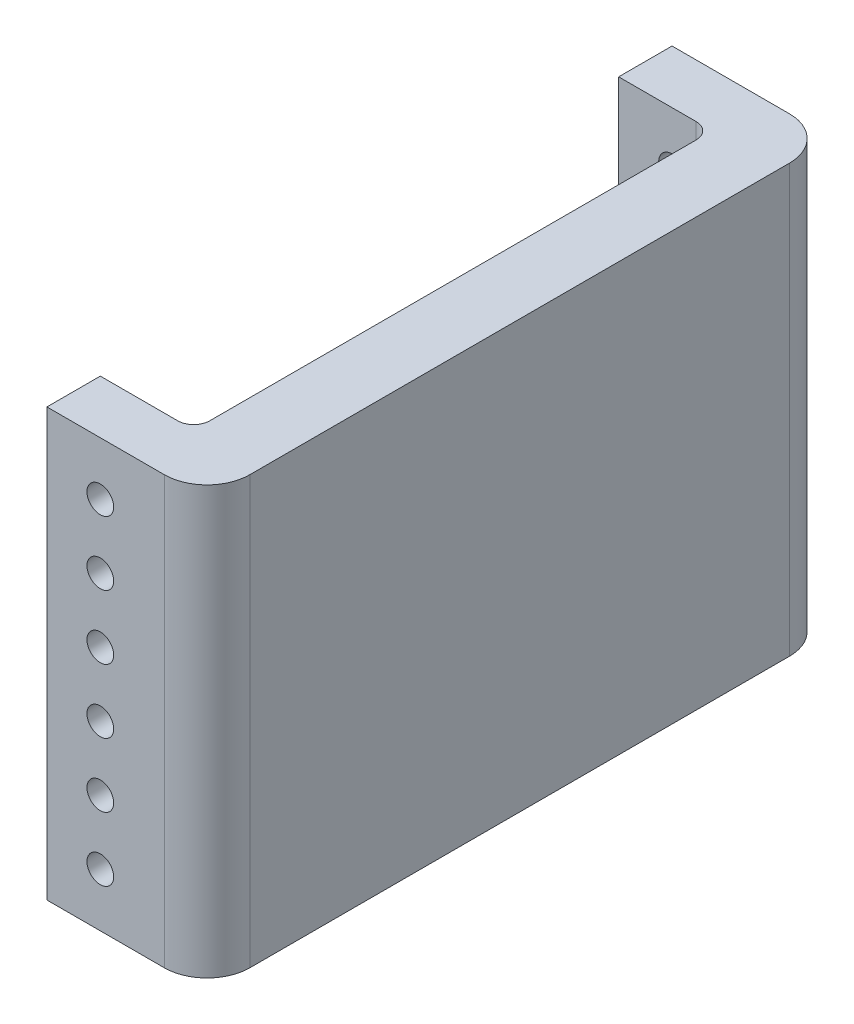
from build123d import *

# Parameters (mm, degrees)
SKETCH1_W           = 297.434
SKETCH1_H           = 203.2
BOSS_EXTRUDE1_DEPTH = 76.2
SKETCH3_W           = 44.45
SKETCH3_H           = 246.634
CUT_EXTRUDE1_DEPTH  = 204.2
SKETCH4_R           = 6.35
CUT_EXTRUDE2_DEPTH  = 298.434
FILLET1_R           = 20.32
FILLET2_R           = 7.62


with BuildPart() as part:
    # Sketch1 → Boss-Extrude1 (new body)
    with BuildSketch(Plane(origin=(0, 0, 0), x_dir=(0, 0, -1), z_dir=(1, 0, 0))):
        with Locations((-688.794526316, 662.857561404)):
            Rectangle(SKETCH1_W, SKETCH1_H)
    extrude(amount=BOSS_EXTRUDE1_DEPTH)

    # Sketch3 → Cut-Extrude1 (cut, through all)
    with BuildSketch(Plane(origin=(0, 764.457561404, 0), x_dir=(1, 0, 0), z_dir=(0, 1, 0))):
        with Locations((22.225, -688.794526316)):
            Rectangle(SKETCH3_W, SKETCH3_H)
    extrude(amount=-CUT_EXTRUDE1_DEPTH, mode=Mode.SUBTRACT)

    # Sketch4 → Cut-Extrude2 (cut, through all)
    with BuildSketch(Plane.XY.offset(837.511526316)):
        with Locations((25.4, 739.057561404)):
            Circle(SKETCH4_R)
        with Locations((25.4, 708.577561404)):
            Circle(SKETCH4_R)
        with Locations((25.4, 678.097561404)):
            Circle(SKETCH4_R)
        with Locations((25.4, 647.617561404)):
            Circle(SKETCH4_R)
        with Locations((25.4, 617.137561404)):
            Circle(SKETCH4_R)
        with Locations((25.4, 586.657561404)):
            Circle(SKETCH4_R)
    extrude(amount=-CUT_EXTRUDE2_DEPTH, mode=Mode.SUBTRACT)

    # Fillet1
    fillet1_edges = [part.edges().sort_by_distance(p)[0] for p in [
        (76.2, 662.857561404, 540.077526316),
        (76.2, 662.857561404, 837.511526316),
    ]]
    fillet(fillet1_edges, radius=FILLET1_R)

    # Fillet2
    fillet2_edges = [part.edges().sort_by_distance(p)[0] for p in [
        (44.45, 662.857561404, 565.477526316),
        (44.45, 662.857561404, 812.111526316),
    ]]
    fillet(fillet2_edges, radius=FILLET2_R)


solid = part.part
